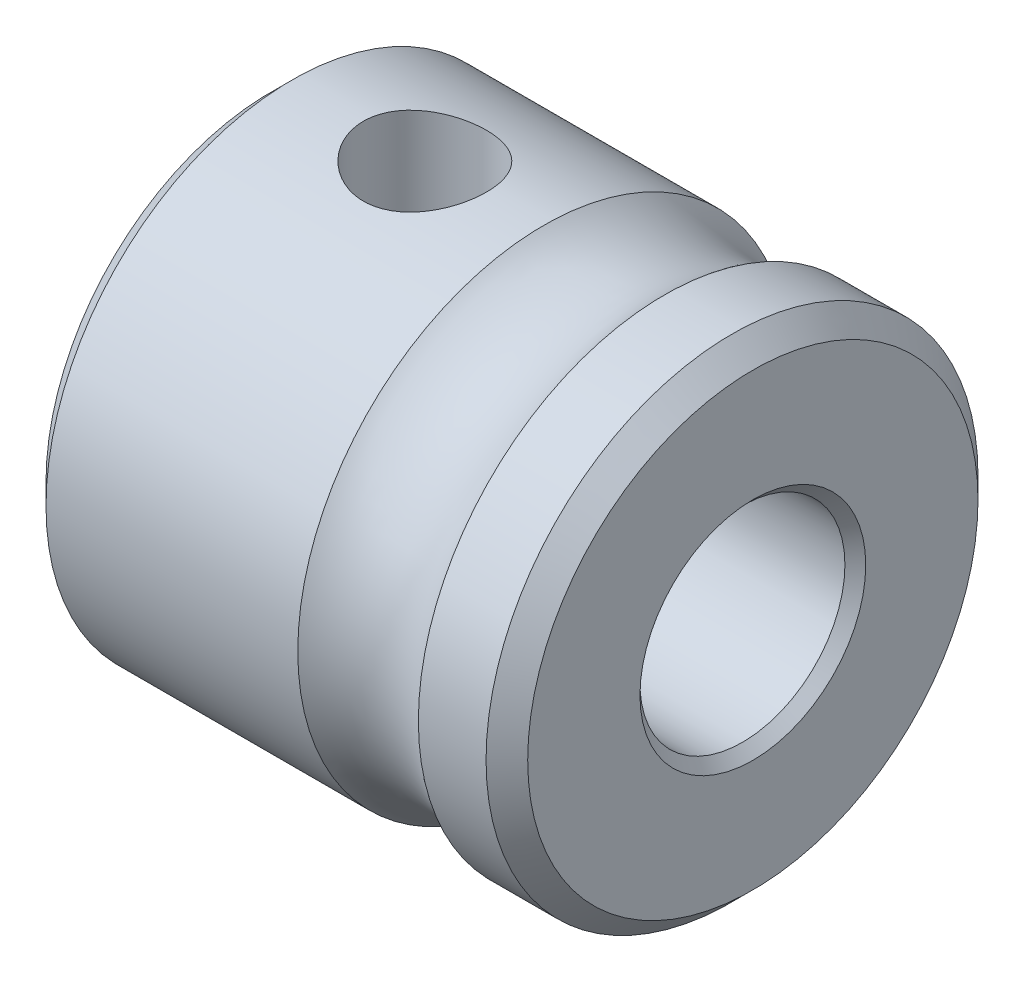
from build123d import *

# Parameters (mm, degrees)
SKETCH1_R           = 6
SKETCH1_R_2         = 2.5
BOSS_EXTRUDE1_DEPTH = 11.75
SKETCH2_R           = 2.413
SKETCH3_R           = 1.5
CUT_EXTRUDE1_DEPTH  = 12
CHAMFER1_SIZE       = 0.508
CHAMFER2_SIZE       = 0.254


with BuildPart() as part:
    # Sketch1 → Boss-Extrude1 (new body)
    with BuildSketch(Plane(origin=(0, 0, 0), x_dir=(0, 0, -1), z_dir=(1, 0, 0))):
        Circle(SKETCH1_R)
        Circle(SKETCH1_R_2, mode=Mode.SUBTRACT)
    extrude(amount=-BOSS_EXTRUDE1_DEPTH)

    # Sketch2 → Cut-Revolve1 (revolve, cut)
    with BuildSketch(Plane(origin=(0, 0, 0), x_dir=(1, 0, 0), z_dir=(0, 1, 0))):
        with Locations((-3.629714112, 7.913)):
            Circle(SKETCH2_R)
    revolve(axis=Axis((0, 0, 0), (1, 0, 0)), mode=Mode.SUBTRACT)

    # Sketch3 → Cut-Extrude1 (cut)
    with BuildSketch(Plane(origin=(0, 0, 0), x_dir=(1, 0, 0), z_dir=(0, 1, 0))):
        with Locations((-8, 0)):
            Circle(SKETCH3_R)
    extrude(amount=CUT_EXTRUDE1_DEPTH, mode=Mode.SUBTRACT)

    # Chamfer1
    chamfer1_edges = [part.edges().sort_by_distance(p)[0] for p in [
        (0, 0, 6),
        (-11.75, 0, 6),
    ]]
    chamfer(chamfer1_edges, length=CHAMFER1_SIZE)

    # Chamfer2
    chamfer2_edges = [part.edges().sort_by_distance(p)[0] for p in [
        (0, 0, 2.5),
    ]]
    chamfer(chamfer2_edges, length=CHAMFER2_SIZE)


solid = part.part
